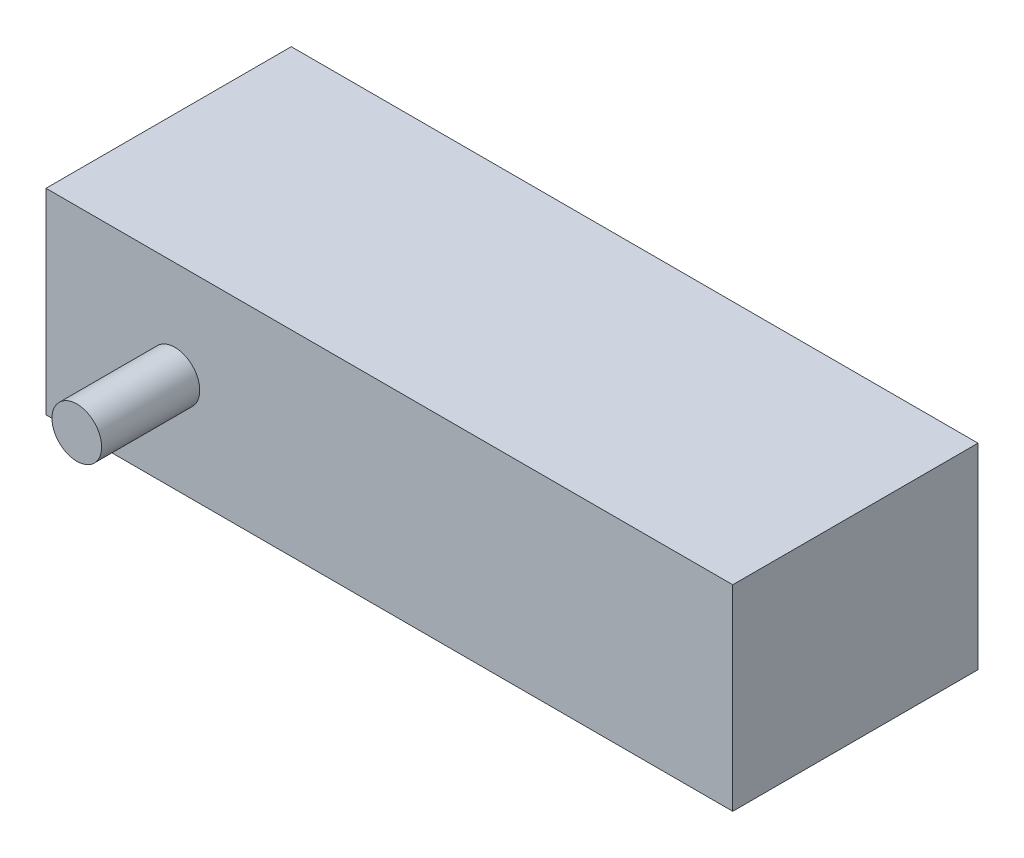
from build123d import *

# Parameters (mm, degrees)
SKETCH1_W           = 70
SKETCH1_H           = 25
BOSS_EXTRUDE1_DEPTH = 20
SKETCH2_R           = 2.531745952
BOSS_EXTRUDE2_DEPTH = 10


with BuildPart() as part:
    # Sketch1 → Boss-Extrude1 (new body)
    with BuildSketch(Plane(origin=(0, 0, 0), x_dir=(1, 0, 0), z_dir=(0, 1, 0))):
        Rectangle(SKETCH1_W, SKETCH1_H)
    extrude(amount=BOSS_EXTRUDE1_DEPTH)

    # Sketch2 → Boss-Extrude2 (add)
    with BuildSketch(Plane.XY.offset(12.5)):
        with Locations((-21.858830372, 10)):
            Circle(SKETCH2_R)
    extrude(amount=BOSS_EXTRUDE2_DEPTH)


solid = part.part
